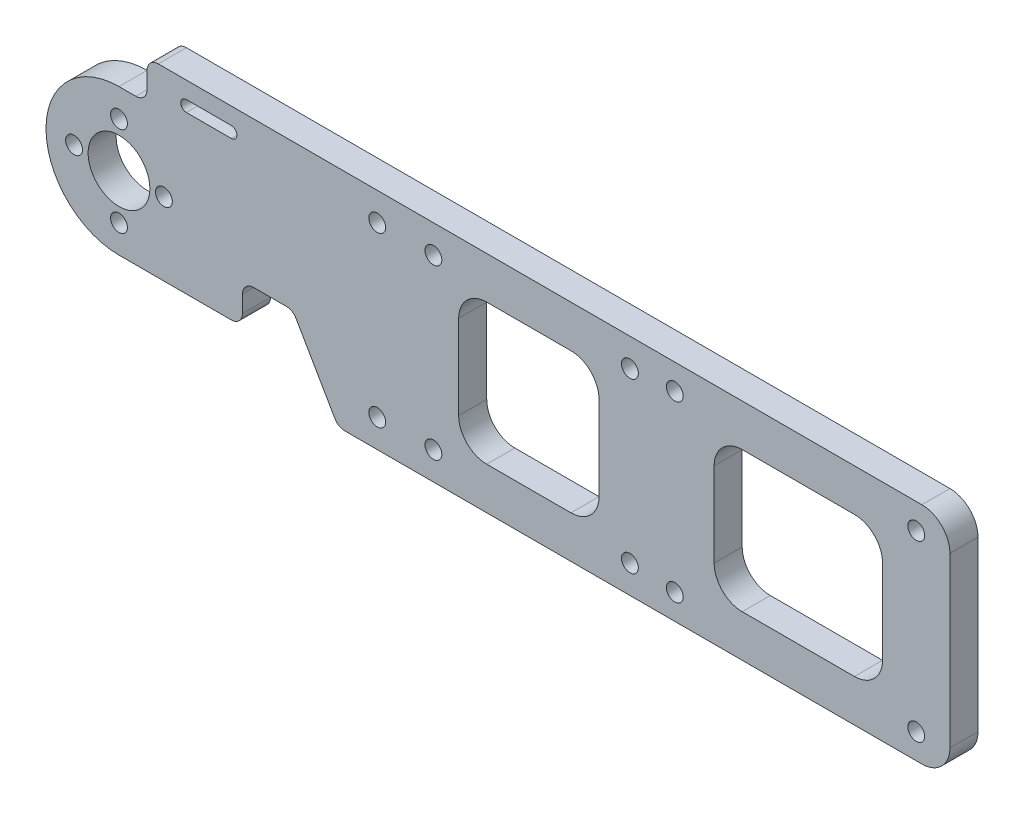
from build123d import *

# Parameters (mm, degrees)
SKETCH2_R           = 5.5
BOSS_EXTRUDE1_DEPTH = 2.5
FILLET1_R           = 5
SKETCH3_R           = 1.5
CUT_EXTRUDE1_DEPTH  = 6
FILLET2_R           = 2
SKETCH4_W           = 25
SKETCH4_H           = 12.5
SKETCH4_W_2         = 30
CUT_EXTRUDE2_DEPTH  = 10
FILLET3_R           = 5
SKETCH5_R           = 2.5
CUT_EXTRUDE3_DEPTH  = 2


with BuildPart() as part:
    # Sketch2 → Boss-Extrude1 (new body, symmetric)
    with BuildSketch(Plane.XY):
        with BuildLine():
            Line((22, -6), (30.958548116, -6))
            Line((30.958548116, -6), (39.041451884, -20))
            Line((39.041451884, -20), (148, -20))
            Line((148, -20), (148, 20))
            Line((148, 20), (5, 20))
            Line((5, 20), (5, 13))
            Line((5, 13), (0, 13))
            ThreePointArc((0, 13), (-13, 0), (0, -13))
            Line((0, -13), (22, -13))
            Line((22, -13), (22, -6))
        make_face()
        Circle(SKETCH2_R, mode=Mode.SUBTRACT)
    extrude(amount=BOSS_EXTRUDE1_DEPTH, both=True)

    # Fillet1
    fillet1_edges = [part.edges().sort_by_distance(p)[0] for p in [
        (148, 20, 0),
        (148, -20, 0),
    ]]
    fillet(fillet1_edges, radius=FILLET1_R)

    # Sketch3 → Cut-Extrude1 (cut, through all)
    with BuildSketch(Plane(origin=(0, 0, -2.5), x_dir=(-1, 0, 0), z_dir=(0, 0, -1))):
        with Locations((-142, 15.5)):
            Circle(SKETCH3_R)
        with Locations((-99, 15.5)):
            Circle(SKETCH3_R)
        with Locations((-91, 15)):
            Circle(SKETCH3_R)
        with Locations((-8, 0)):
            Circle(SKETCH3_R)
        with Locations((0, 8)):
            Circle(SKETCH3_R)
        with Locations((0, -8)):
            Circle(SKETCH3_R)
        with Locations((8, 0)):
            Circle(SKETCH3_R)
        with BuildLine():
            Line((-12, 17), (-20, 17))
            ThreePointArc((-20, 17), (-21, 16), (-20, 15))
            Line((-20, 15), (-12, 15))
            ThreePointArc((-12, 15), (-11, 16), (-12, 17))
        make_face()
        with Locations((-56, -15)):
            Circle(SKETCH3_R)
        with Locations((-91, -15)):
            Circle(SKETCH3_R)
        with Locations((-46, -15)):
            Circle(SKETCH3_R)
        with Locations((-46, 15)):
            Circle(SKETCH3_R)
        with Locations((-56, 15)):
            Circle(SKETCH3_R)
        with Locations((-142, -15.5)):
            Circle(SKETCH3_R)
        with Locations((-99, -15.5)):
            Circle(SKETCH3_R)
    extrude(amount=-CUT_EXTRUDE1_DEPTH, mode=Mode.SUBTRACT)

    # Fillet2
    fillet2_edges = [part.edges().sort_by_distance(p)[0] for p in [
        (22, -13, 0),
        (5, 13, 0),
        (5, 20, 0),
        (39.041451884, -20, 0),
        (30.958548116, -6, 0),
        (22, -6, 0),
    ]]
    fillet(fillet2_edges, radius=FILLET2_R)

    # Sketch4 → Cut-Extrude2 (cut)
    with BuildSketch(Plane.XY.offset(2.5)):
        with Locations((73, 6.25)):
            Rectangle(SKETCH4_W, SKETCH4_H)
        with Locations((73, -6.25)):
            Rectangle(SKETCH4_W, SKETCH4_H)
        with Locations((121, 6.25)):
            Rectangle(SKETCH4_W_2, SKETCH4_H)
        with Locations((121, -6.25)):
            Rectangle(SKETCH4_W_2, SKETCH4_H)
    extrude(amount=-CUT_EXTRUDE2_DEPTH, mode=Mode.SUBTRACT)

    # Fillet3
    fillet3_edges = [part.edges().sort_by_distance(p)[0] for p in [
        (60.5, -12.5, 0),
        (60.5, 12.5, 0),
        (85.5, 12.5, 0),
        (85.5, -12.5, 0),
        (136, 12.5, 0),
        (136, -12.5, 0),
        (106, -12.5, 0),
        (106, 12.5, 0),
    ]]
    fillet(fillet3_edges, radius=FILLET3_R)

    # Sketch5 → Cut-Extrude3 (cut)
    with BuildSketch(Plane(origin=(0, 0, -2.5), x_dir=(-1, 0, 0), z_dir=(0, 0, -1))):
        with Locations((-99, 15.5)):
            Circle(SKETCH5_R)
        with Locations((-99, -15.5)):
            Circle(SKETCH5_R)
    extrude(amount=-CUT_EXTRUDE3_DEPTH, mode=Mode.SUBTRACT)


solid = part.part
